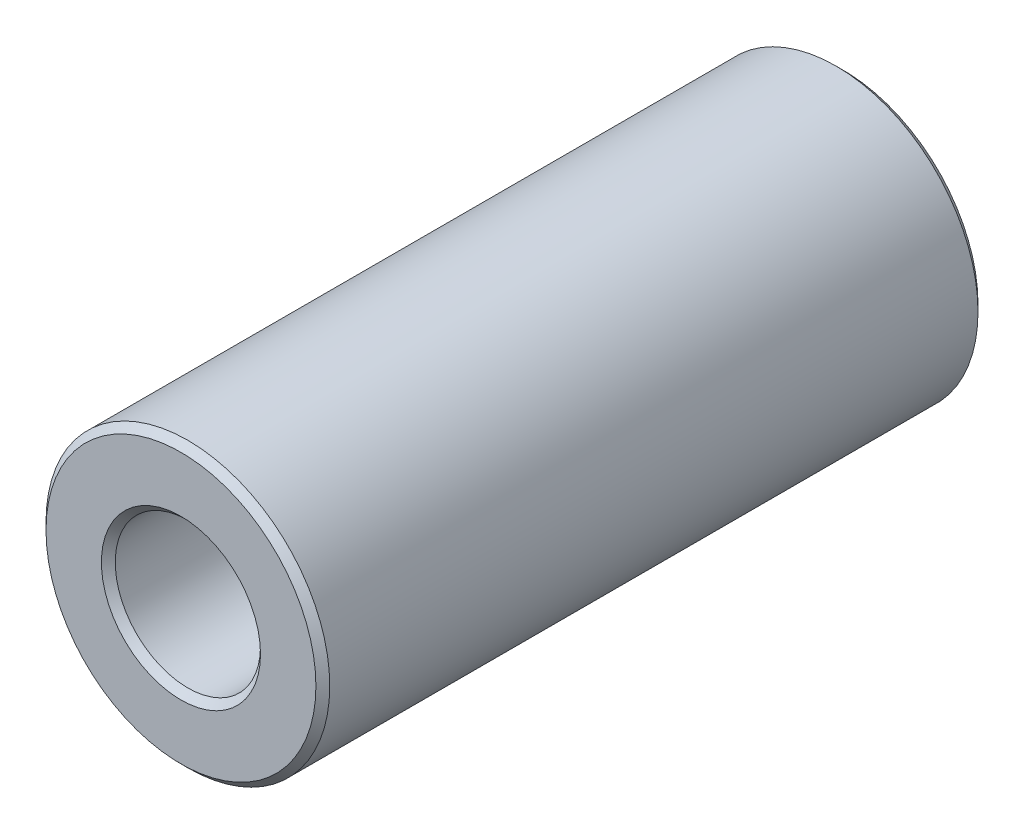
from build123d import *

# Parameters (mm, degrees)
BOSS_EXTRUDE1_DEPTH      = 11.1125
BOSS_EXTRUDE1_DEPTH_BACK = 11.1125
SKETCH3_R                = 4.7625
SKETCH3_R_2              = 2.4384
CHAMFER1_SIZE            = 0.23241


with BuildPart() as part:
    # Sketch3 → Boss-Extrude1 (new, two sides: drawn at the far end of the back side and taken through both)
    with BuildSketch(Plane.XY.offset(-BOSS_EXTRUDE1_DEPTH_BACK)):
        Circle(SKETCH3_R)
        Circle(SKETCH3_R_2, mode=Mode.SUBTRACT)
    extrude(amount=BOSS_EXTRUDE1_DEPTH + BOSS_EXTRUDE1_DEPTH_BACK)

    # Chamfer1
    chamfer1_edges = [part.edges().sort_by_distance(p)[0] for p in [
        (-4.7625, 0, -11.1125),
        (-2.4384, 0, -11.1125),
        (-4.7625, 0, 11.1125),
        (-2.4384, 0, 11.1125),
    ]]
    chamfer(chamfer1_edges, length=CHAMFER1_SIZE)


solid = part.part
